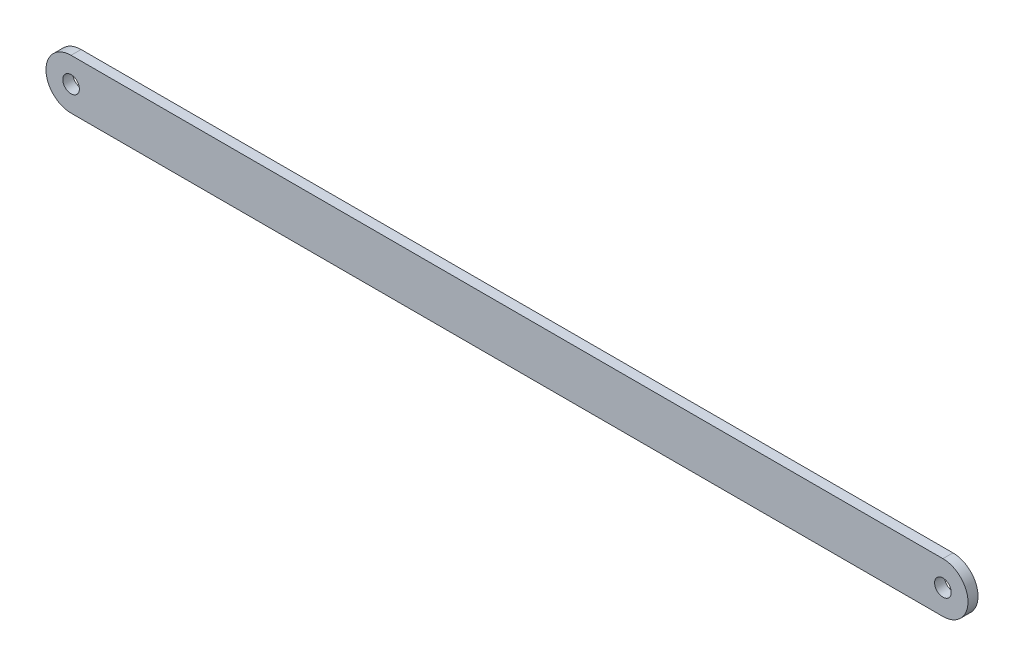
from build123d import *

# Parameters (mm, degrees)
SKICA1_R                = 4.15
P_IDAT_VYSUNUT_M1_DEPTH = 5


with BuildPart() as part:
    # Skica1 → Přidat vysunutím1 (new body)
    with BuildSketch(Plane.XY):
        with BuildLine():
            Line((0, 12.5), (435, 12.5))
            ThreePointArc((435, 12.5), (447.5, 0), (435, -12.5))
            Line((435, -12.5), (0, -12.5))
            ThreePointArc((0, -12.5), (-12.5, 0), (0, 12.5))
        make_face()
        Circle(SKICA1_R, mode=Mode.SUBTRACT)
        with Locations((435, 0)):
            Circle(SKICA1_R, mode=Mode.SUBTRACT)
    extrude(amount=P_IDAT_VYSUNUT_M1_DEPTH)


solid = part.part
